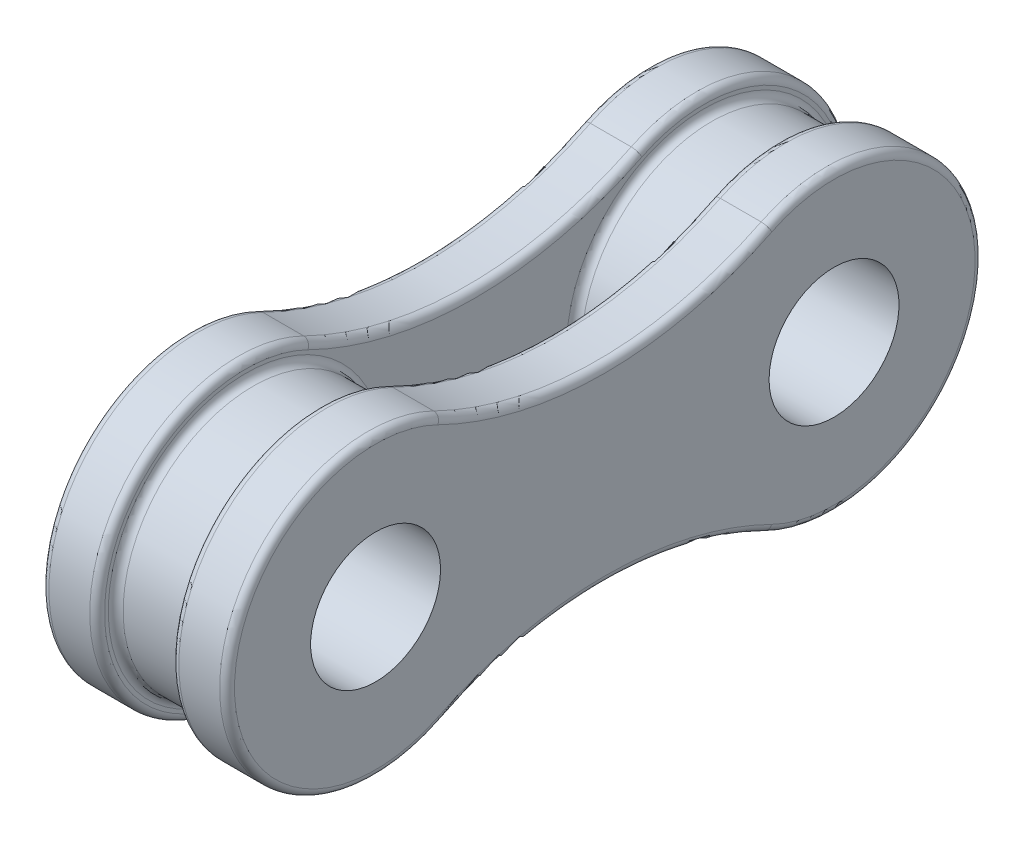
from build123d import *

# Parameters (mm, degrees)
SALIENTE_EXTRUIR1_START      = 1
CROQUIS1_R                   = 1.75
SALIENTE_EXTRUIR1_DEPTH      = 1.5
SALIENTE_EXTRUIR2_START      = -1
CROQUIS2_R                   = 1.75
SALIENTE_EXTRUIR2_DEPTH      = 1.5
CROQUIS3_R                   = 3.5
CROQUIS3_R_2                 = 1.75
SALIENTE_EXTRUIR3_DEPTH      = 1
SALIENTE_EXTRUIR3_DEPTH_BACK = 2.5
REDONDEO1_R                  = 0.2


with BuildPart() as part:
    # Croquis1 → Saliente-Extruir1 (new body)
    with BuildSketch(Plane(origin=(0, 0, 0), x_dir=(0, 0, -1), z_dir=(1, 0, 0)).offset(SALIENTE_EXTRUIR1_START)):
        with BuildLine():
            ThreePointArc((-4.410714286, 3.589888009), (-10.175, 0), (-4.410714286, -3.589888009))
            ThreePointArc((-4.410714286, -3.589888009), (0, -2.564608032), (4.410714286, -3.589888009))
            ThreePointArc((4.410714286, -3.589888009), (10.175, 0), (4.410714286, 3.589888009))
            ThreePointArc((4.410714286, 3.589888009), (0, 2.564608032), (-4.410714286, 3.589888009))
        make_face()
        with Locations((-6.175, 0)):
            Circle(CROQUIS1_R, mode=Mode.SUBTRACT)
        with Locations((6.175, 0)):
            Circle(CROQUIS1_R, mode=Mode.SUBTRACT)
    extrude(amount=SALIENTE_EXTRUIR1_DEPTH)



with BuildPart() as body_2:
    # Croquis2 → Saliente-Extruir2 (new body)
    with BuildSketch(Plane(origin=(0, 0, 0), x_dir=(0, 0, -1), z_dir=(1, 0, 0)).offset(SALIENTE_EXTRUIR2_START)):
        with BuildLine():
            ThreePointArc((-4.410714286, 3.589888009), (0, 2.564608032), (4.410714286, 3.589888009))
            ThreePointArc((4.410714286, 3.589888009), (10.175, 0), (4.410714286, -3.589888009))
            ThreePointArc((4.410714286, -3.589888009), (0, -2.564608032), (-4.410714286, -3.589888009))
            ThreePointArc((-4.410714286, -3.589888009), (-10.175, 0), (-4.410714286, 3.589888009))
        make_face()
        with Locations((6.175, 0)):
            Circle(CROQUIS2_R, mode=Mode.SUBTRACT)
        with Locations((-6.175, 0)):
            Circle(CROQUIS2_R, mode=Mode.SUBTRACT)
    extrude(amount=-SALIENTE_EXTRUIR2_DEPTH)


with BuildPart() as part_1:
    add(part.part)

    add(body_2.part)  # Saliente-Extruir3 merges body 2
    # Croquis3 → Saliente-Extruir3 (add, two sides)
    with BuildSketch(Plane(origin=(0, 0, 0), x_dir=(0, 0, -1), z_dir=(1, 0, 0))) as saliente_extruir3_sk:
        with Locations((-6.175, 0)):
            Circle(CROQUIS3_R)
        with Locations((-6.175, 0)):
            Circle(CROQUIS3_R_2, mode=Mode.SUBTRACT)
        with Locations((6.175, 0)):
            Circle(CROQUIS3_R)
        with Locations((6.175, 0)):
            Circle(CROQUIS3_R_2, mode=Mode.SUBTRACT)
    extrude(amount=SALIENTE_EXTRUIR3_DEPTH)
    extrude(saliente_extruir3_sk.sketch, amount=-SALIENTE_EXTRUIR3_DEPTH_BACK)

    # Redondeo1
    redondeo1_edges = [part_1.edges().sort_by_distance(p)[0] for p in [
        (2.5, -2.564608032, 0),
        (2.5, 0, -10.175),
        (-1, 0, -2.675),
        (1, 0, -2.675),
        (-2.5, 0, 10.175),
        (-2.5, 2.564608032, 0),
        (-2.5, 0, -10.175),
        (-2.5, -2.564608032, 0),
        (-2.5, 0, 7.925),
        (-2.5, 0, -4.425),
        (-1, 0, 10.175),
        (-1, -2.564608032, 0),
        (-1, 0, -10.175),
        (-1, 2.564608032, 0),
        (-1, 0, 9.675),
        (1, 0, 9.675),
        (2.5, 2.564608032, 0),
        (1, 0, -10.175),
        (1, -2.564608032, 0),
        (1, 0, 10.175),
        (1, 2.564608032, 0),
        (2.5, 0, 10.175),
    ]]
    fillet(redondeo1_edges, radius=REDONDEO1_R)


solid = part_1.part
